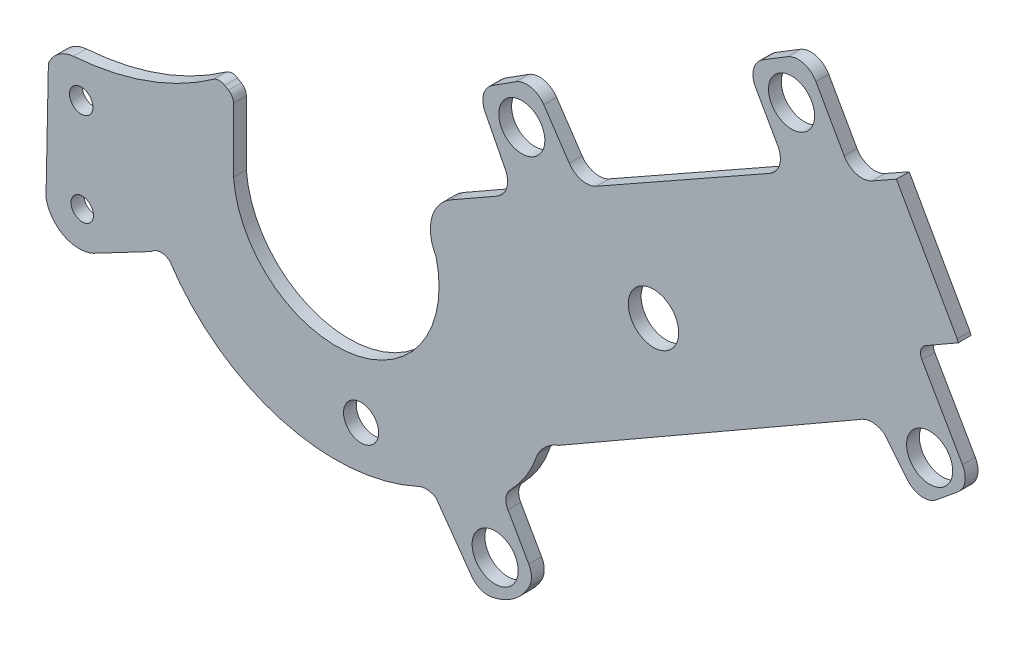
from build123d import *

# Parameters (mm, degrees)
ESBO_O1_R                = 49.227306986
ESBO_O1_R_2              = 45.027223586
ESBO_O1_R_3              = 34.289668097
ESBO_O1_R_4              = 45
ESBO_O1_R_5              = 22.918852427
ESBO_O1_R_6              = 21.929059038
RESSALTO_EXTRUS_O1_DEPTH = 25


with BuildPart() as part:
    # Esboço1 → Ressalto-extrusão1 (new body)
    with BuildSketch(Plane.XY):
        with BuildLine():
            Line((8592.065409332, 5198.475728322), (8473.447242619, 5409.224509958))
            Line((8473.447242619, 5409.224509958), (8425.902270717, 5382.464225227))
            ThreePointArc((8425.902270717, 5382.464225227), (8395.507573393, 5378.800801313), (8371.424844911, 5397.702666012))
            Line((8371.424844911, 5397.702666012), (8316.40665203, 5495.453435889))
            ThreePointArc((8316.40665203, 5495.453435889), (8292.016223819, 5514.440048301), (8261.375488437, 5510.374365776))
            Line((8261.375488437, 5510.374365776), (8212.449282848, 5480.477339997))
            ThreePointArc((8212.449282848, 5480.477339997), (8194.592026382, 5456.406171561), (8198.470371474, 5426.686460968))
            Line((8198.470371474, 5426.686460968), (8241.716603514, 5350.053723792))
            ThreePointArc((8241.716603514, 5350.053723792), (8245.414384596, 5319.663187185), (8226.539756155, 5295.559106588))
            Line((8226.539756155, 5295.559106588), (7887.56689815, 5104.266202112))
            ThreePointArc((7887.56689815, 5104.266202112), (7858.690563236, 5100.178437433), (7834.71418175, 5116.782222212))
            Line((7834.71418175, 5116.782222212), (7814.875485509, 5146.286291727))
            Line((7814.875485509, 5146.286291727), (7784.878848462, 5190.897230564))
            ThreePointArc((7784.878848462, 5190.897230564), (7759.841470177, 5207.737092835), (7730.162808648, 5202.293902357))
            Line((7730.162808648, 5202.293902357), (7684.418563925, 5173.093939339))
            ThreePointArc((7684.418563925, 5173.093939339), (7667.337308495, 5149.854796663), (7670.325681174, 5121.168621105))
            Line((7670.325681174, 5121.168621105), (7709.87388758, 5043.81577039))
            ThreePointArc((7709.87388758, 5043.81577039), (7712.586860583, 5014.16308224), (7694.060285678, 4990.851965593))
            Line((7694.060285678, 4990.851965593), (7603.245211769, 4939.110334103))
            ThreePointArc((7603.245211769, 4939.110334103), (7566.042022636, 4889.986984267), (7574.591315044, 4828.961658539))
            ThreePointArc((7574.591315044, 4828.961658539), (7411.369433565, 4582.346099234), (7179.112865973, 4765.423961074))
            Line((7179.112865973, 4765.423961074), (7179.112865973, 4890.398526732))
            ThreePointArc((7179.112865973, 4890.398526732), (7176.529401806, 4900.23032614), (7169.446438014, 4907.522115401))
            Line((7169.446438014, 4907.522115401), (7161.87645403, 4912.09037363))
            ThreePointArc((7161.87645403, 4912.09037363), (7150.814869868, 4914.953530528), (7139.99090215, 4911.293197972))
            ThreePointArc((7139.99090215, 4911.293197972), (7010.077113446, 4843.731348706), (6866.77493755, 4813.620182095))
            ThreePointArc((6866.77493755, 4813.620182095), (6837.238365249, 4802.28095325), (6817.644330707, 4777.440240208))
            Line((6817.644330707, 4777.440240208), (6812.984670077, 4548.041588809))
            ThreePointArc((6812.984670077, 4548.041588809), (6847.319630156, 4501.148504338), (6905.423739633, 4499.820604987))
            Line((6905.423739633, 4499.820604987), (7018.783227578, 4559.423081996))
            ThreePointArc((7018.783227578, 4559.423081996), (7036.263274842, 4567.468257298), (7054.527862902, 4561.411713646))
            ThreePointArc((7054.527862902, 4561.411713646), (7271.453583291, 4402.062402746), (7539.814575965, 4422.831337767))
            ThreePointArc((7539.814575965, 4422.831337767), (7557.472949269, 4426.146472293), (7574.591376366, 4420.690492236))
            Line((7574.591376366, 4420.690492236), (7643.824786877, 4323.537498877))
            ThreePointArc((7643.824786877, 4323.537498877), (7661.638348099, 4309.574510741), (7684.1782089, 4307.51473498))
            ThreePointArc((7684.1782089, 4307.51473498), (7726.117997258, 4326.065711445), (7756.109950671, 4360.758179011))
            ThreePointArc((7756.109950671, 4360.758179011), (7760.853190032, 4380.173039859), (7755.611379393, 4399.459267136))
            Line((7755.611379393, 4399.459267136), (7714.866132222, 4470.97387784))
            ThreePointArc((7714.866132222, 4470.97387784), (7711.192216927, 4489.765596658), (7719.63329346, 4506.952061587))
            ThreePointArc((7719.63329346, 4506.952061587), (7751.230180611, 4547.174632919), (7772.780877122, 4593.561980354))
            ThreePointArc((7772.780877122, 4593.561980354), (7790.429838997, 4615.627863403), (7814.875485509, 4629.798234485))
            Line((7814.875485509, 4629.798234485), (8402.08207018, 4967.132328945))
            ThreePointArc((8402.08207018, 4967.132328945), (8425.846622391, 4974.638589154), (8449.611174603, 4967.132328945))
            Line((8449.611174603, 4967.132328945), (8495.089773791, 4911.541656895))
            ThreePointArc((8495.089773791, 4911.541656895), (8522.067187452, 4897.068320984), (8551.377293559, 4905.910039154))
            Line((8551.377293559, 4905.910039154), (8593.116417231, 4940.056718911))
            ThreePointArc((8593.116417231, 4940.056718911), (8607.129643298, 4963.786364709), (8602.468925751, 4990.947813611))
            Line((8602.468925751, 4990.947813611), (8523.158682911, 5128.94606196))
            ThreePointArc((8523.158682911, 5128.94606196), (8521.190660044, 5144.12636041), (8530.533149704, 5156.2520547))
            Line((8530.533149704, 5156.2520547), (8594.238523916, 5192.864756379))
            Line((8594.238523916, 5192.864756379), (8592.065409332, 5198.475728322))
        make_face()
        with Locations((7999.136389936, 4936.736467004)):
            Circle(ESBO_O1_R, mode=Mode.SUBTRACT)
        with Locations((8538.305471244, 4970.64052635)):
            Circle(ESBO_O1_R_2, mode=Mode.SUBTRACT)
        with Locations((7428.160556208, 4474.796077944)):
            Circle(ESBO_O1_R_3, mode=Mode.SUBTRACT)
        with Locations((7689.94786831, 4377.665287462)):
            Circle(ESBO_O1_R_4, mode=Mode.SUBTRACT)
        with Locations((6881.727296698, 4746.283471792)):
            Circle(ESBO_O1_R_5, mode=Mode.SUBTRACT)
        with Locations((6883.815097675, 4563.962455068)):
            Circle(ESBO_O1_R_6, mode=Mode.SUBTRACT)
        with Locations((7741.989693859, 5131.410658858)):
            Circle(ESBO_O1_R_4, mode=Mode.SUBTRACT)
        with Locations((8268.711651115, 5436.402584307)):
            Circle(ESBO_O1_R_4, mode=Mode.SUBTRACT)
    extrude(amount=RESSALTO_EXTRUS_O1_DEPTH)


solid = part.part
